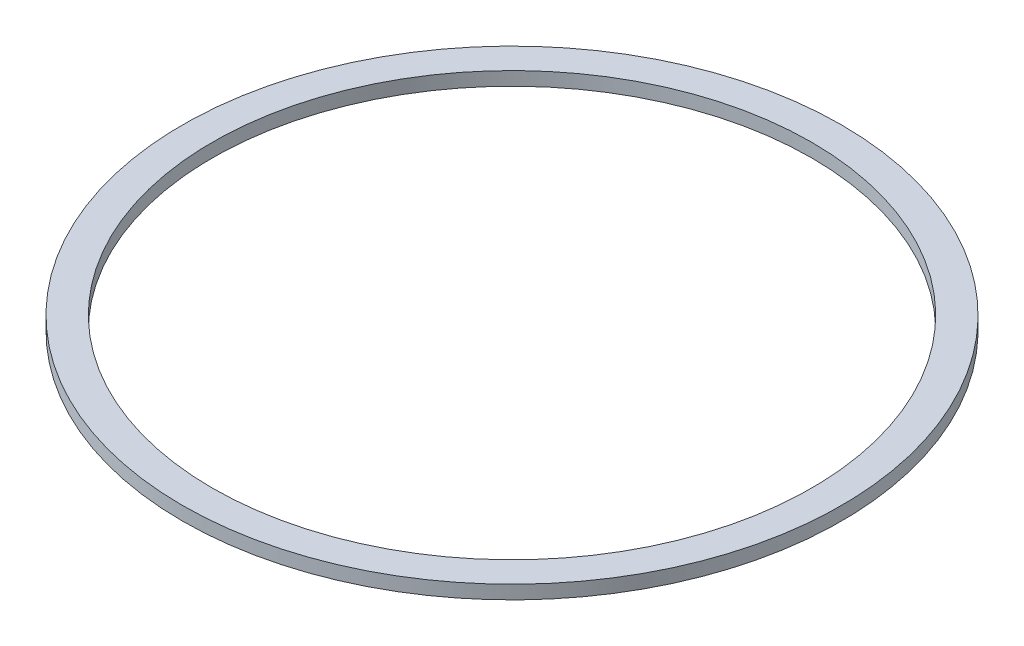
from build123d import *

# Parameters (mm, degrees)
SKETCH1_R           = 41.91
SKETCH1_R_2         = 38.1
BOSS_EXTRUDE1_DEPTH = 1.7272


with BuildPart() as part:
    # Sketch1 → Boss-Extrude1 (new body)
    with BuildSketch(Plane(origin=(0, 0, 0), x_dir=(1, 0, 0), z_dir=(0, 1, 0))):
        Circle(SKETCH1_R)
        Circle(SKETCH1_R_2, mode=Mode.SUBTRACT)
    extrude(amount=BOSS_EXTRUDE1_DEPTH)


solid = part.part
